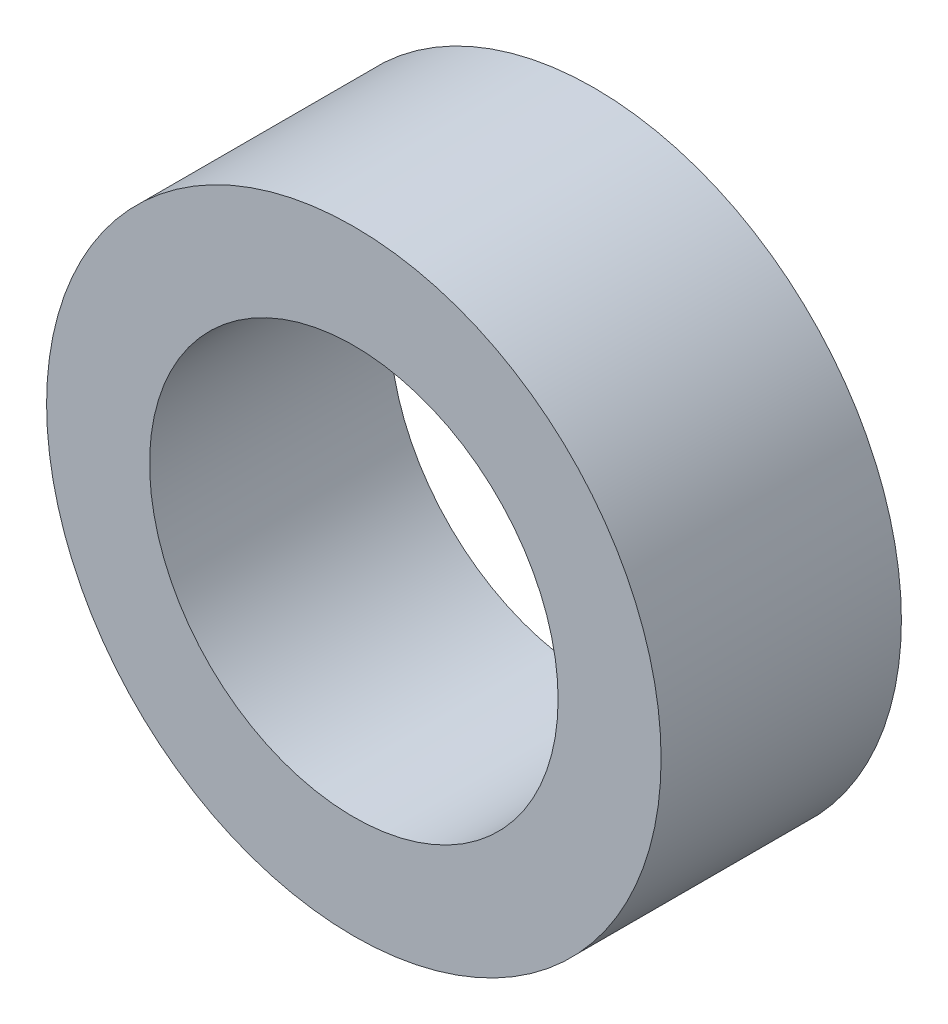
from build123d import *

# Parameters (mm, degrees)
SKETCH_1_R      = 8.95
SKETCH_1_R_2    = 5.95
EXTRUDE_1_DEPTH = 7


with BuildPart() as part:
    # 草图1 → 拉伸-薄壁1 (new body)
    with BuildSketch(Plane.XY):
        Circle(SKETCH_1_R)
        Circle(SKETCH_1_R_2, mode=Mode.SUBTRACT)
    extrude(amount=EXTRUDE_1_DEPTH)


solid = part.part
